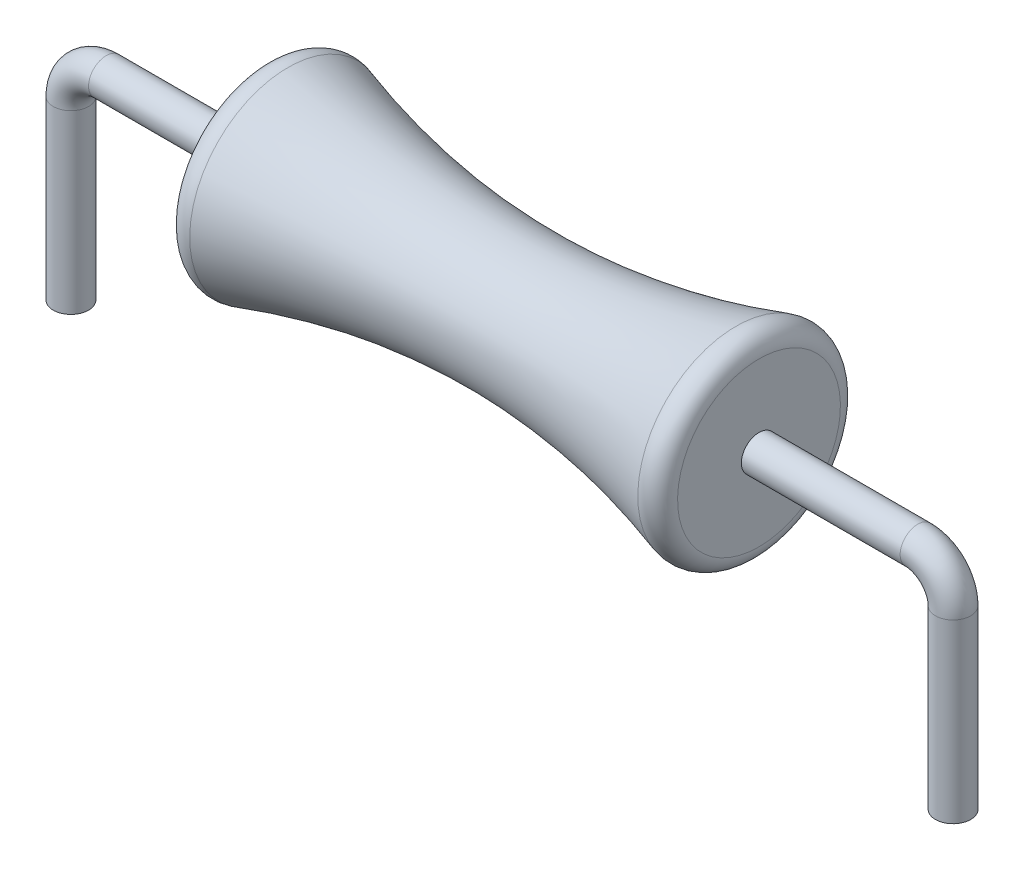
from build123d import *

# Parameters (mm, degrees)
FILLET2_R = 0.25
SKETCH4_R = 0.25


with BuildPart() as part:
    # Sketch1 → Revolve1 (revolve)
    with BuildSketch(Plane.XY):
        with BuildLine():
            Line((-3.5, 0), (3.5, 0))
            Line((3.5, 0), (3.5, 1.5))
            add(Edge.make_bspline(
                [(-3.5, 1.5), (0, 0.282452635), (3.5, 1.5)],
                knots=[0, 0, 0, 1, 1, 1], degree=2))
            Line((-3.5, 1.5), (-3.5, 0))
        make_face()
    revolve(axis=Axis((-3.5, 0, 0), (1, 0, 0)))

    # Fillet2
    fillet2_edges = [part.edges().sort_by_distance(p)[0] for p in [
        (3.5, -1.5, 0),
        (-3.5, -1.5, 0),
    ]]
    fillet(fillet2_edges, radius=FILLET2_R)

    # Sweep1: sweep along a path in Sketch3
    with BuildLine(Plane.XY) as sweep1_path:
        Line((3.5, 0), (5.75, 0))
        ThreePointArc((5.75, 0), (6.103553391, -0.146446609), (6.25, -0.5))
        Line((6.25, -0.5), (6.25, -3))
    # Sketch4 → Sweep1 (sweep)
    with BuildSketch(Plane(origin=(3.5, 0, 0), x_dir=(0, 0, -1), z_dir=(1, 0, 0))):
        Circle(SKETCH4_R)
    sweep1 = sweep(path=sweep1_path.line)

    # Mirror1: Sweep1 across plane
    add(sweep1.mirror(Plane(origin=(0, 0, 0), x_dir=(0, 0, 1), z_dir=(1, 0, 0))))


solid = part.part
